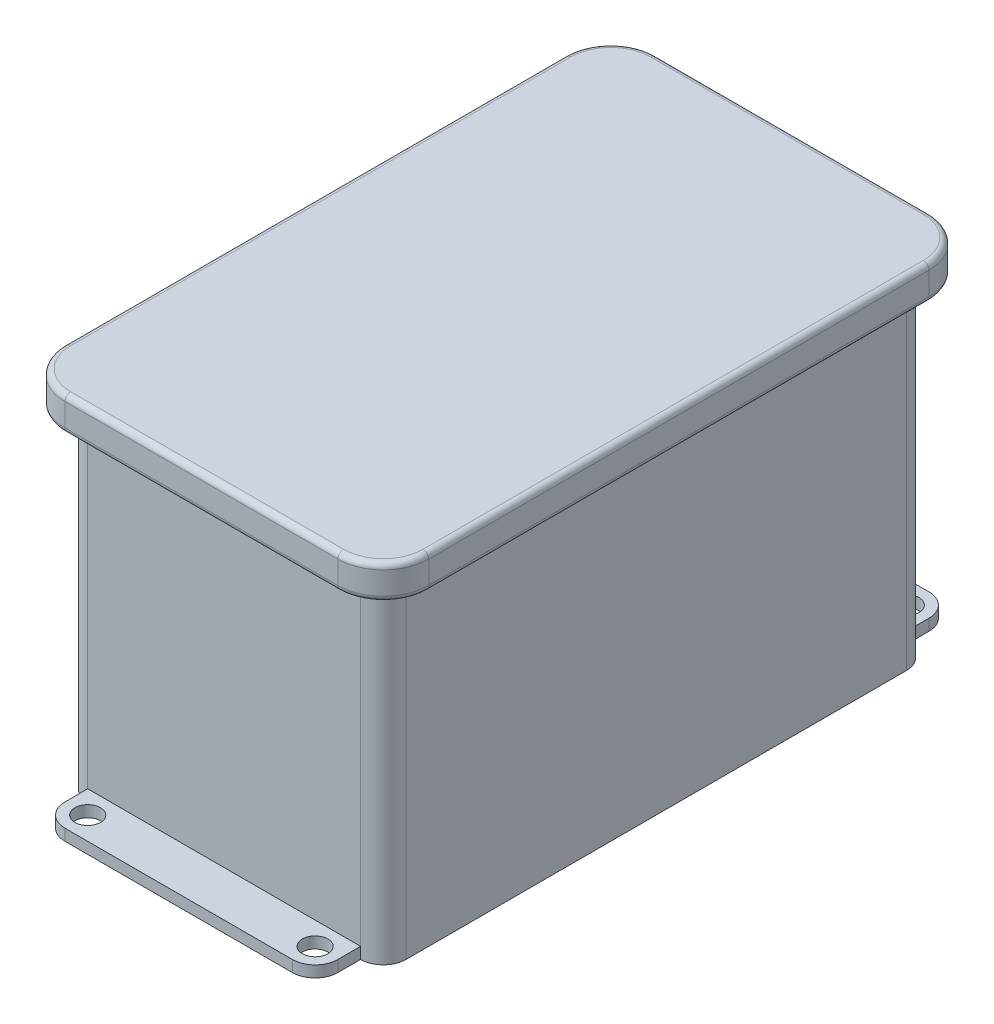
from build123d import *

# Parameters (mm, degrees)
SKETCH1_W           = 88.9
SKETCH1_H           = 152.4
BOSS_EXTRUDE1_DEPTH = 101.6
SKETCH2_R           = 3.571875
BOSS_EXTRUDE2_DEPTH = 3.175
FILLET1_R           = 6.35
BOSS_EXTRUDE3_DEPTH = 9.525
FILLET2_R           = 1.5875


with BuildPart() as part:
    # Sketch1 → Boss-Extrude1 (new body)
    with BuildSketch(Plane(origin=(0, 0, 0), x_dir=(1, 0, 0), z_dir=(0, 1, 0))):
        with Locations((44.45, 76.2)):
            Rectangle(SKETCH1_W, SKETCH1_H)
    extrude(amount=BOSS_EXTRUDE1_DEPTH)

    # Fillet1
    fillet1_edges = [part.edges().sort_by_distance(p)[0] for p in [
        (0, 50.8, -152.4),
        (88.9, 50.8, -152.4),
        (88.9, 50.8, 0),
        (0, 50.8, 0),
    ]]
    fillet(fillet1_edges, radius=FILLET1_R)

    # Sketch4 → Boss-Extrude3 (add)
    with BuildSketch(Plane(origin=(0, 101.6, 0), x_dir=(1, 0, 0), z_dir=(0, 1, 0))):
        with BuildLine():
            Line((95.25, 6.35), (95.25, 146.05))
            ThreePointArc((95.25, 146.05), (91.530256121, 155.030256121), (82.55, 158.75))
            Line((82.55, 158.75), (6.35, 158.75))
            ThreePointArc((6.35, 158.75), (-2.630256121, 155.030256121), (-6.35, 146.05))
            Line((-6.35, 146.05), (-6.35, 6.35))
            ThreePointArc((-6.35, 6.35), (-2.630256121, -2.630256121), (6.35, -6.35))
            Line((6.35, -6.35), (82.55, -6.35))
            ThreePointArc((82.55, -6.35), (91.530256121, -2.630256121), (95.25, 6.35))
        make_face()
    extrude(amount=-BOSS_EXTRUDE3_DEPTH)

    # Fillet2
    fillet2_edges = [part.edges().sort_by_distance(p)[0] for p in [
        (91.530256121, 92.075, 2.630256121),
        (44.45, 92.075, 6.35),
        (-2.630256121, 92.075, 2.630256121),
        (-6.35, 92.075, -76.2),
        (-2.630256121, 92.075, -155.030256121),
        (44.45, 92.075, -158.75),
        (91.530256121, 92.075, -155.030256121),
        (95.25, 92.075, -76.2),
        (91.530256121, 101.6, 2.630256121),
        (95.25, 101.6, -76.2),
        (91.530256121, 101.6, -155.030256121),
        (44.45, 101.6, -158.75),
        (-2.630256121, 101.6, -155.030256121),
        (-6.35, 101.6, -76.2),
        (-2.630256121, 101.6, 2.630256121),
        (44.45, 101.6, 6.35),
    ]]
    fillet(fillet2_edges, radius=FILLET2_R)


with BuildPart() as body_2:
    # Sketch2 → Boss-Extrude2 (new body)
    with BuildSketch(Plane.XZ):
        with BuildLine():
            Line((12.7, -165.1), (76.2, -165.1))
            ThreePointArc((76.2, -165.1), (80.690128061, -163.240128061), (82.55, -158.75))
            Line((82.55, -158.75), (82.55, -152.4))
            Line((82.55, -152.4), (6.35, -152.4))
            Line((6.35, -152.4), (6.35, -158.75))
            ThreePointArc((6.35, -158.75), (8.209871939, -163.240128061), (12.7, -165.1))
        make_face()
        with Locations((12.7, -158.75)):
            Circle(SKETCH2_R, mode=Mode.SUBTRACT)
        with Locations((76.2, -158.75)):
            Circle(SKETCH2_R, mode=Mode.SUBTRACT)
    extrude(amount=-BOSS_EXTRUDE2_DEPTH)


with BuildPart() as body_3:
    # Mirror2: mirrored copy
    add(body_2.part.mirror(Plane(origin=(0, 0, -76.2), x_dir=(1, 0, 0), z_dir=(0, 0, -1))))


solid = Compound([part.part, body_2.part, body_3.part])
